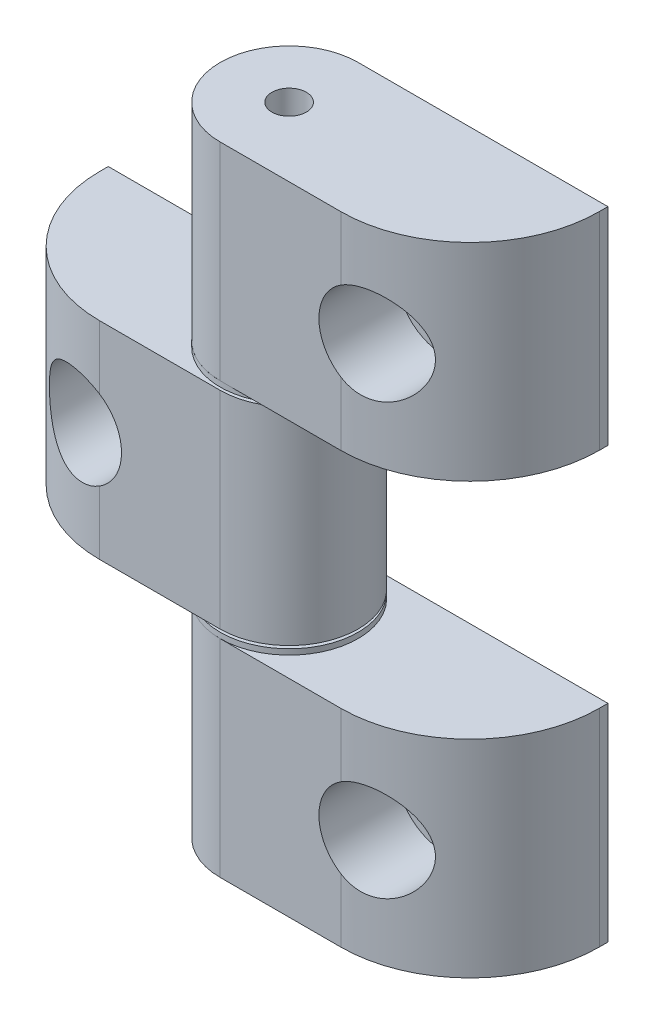
from build123d import *

# Parameters (mm, degrees)
SKETCH1_W           = 29.3624
SKETCH1_H           = 19.05
SKETCH1_R           = 2.413
EXTRUDE1_DEPTH      = 6.35
SKETCH2_R           = 4.191
SKETCH2_R_2         = 2.413
EXTRUDE2_DEPTH      = 2.159
SKETCH3_R           = 1.5875
CUT_EXTRUDE1_DEPTH  = 20.05
SKETCH4_R           = 4.3434
CUT_EXTRUDE2_DEPTH  = 7.1501
LPATTERN1_COUNT     = 2
LPATTERN1_PITCH     = 19.812
LPATTERN1_2_COUNT   = 2
LPATTERN1_2_PITCH   = 19.812
SKETCH5_R           = 6.35
SKETCH5_R_2         = 1.5875
EXTRUDE3_DEPTH      = 0.508
SKETCH6_R           = 6.35
SKETCH6_R_2         = 1.5875
EXTRUDE4_DEPTH      = 0.508
SKETCH7_R           = 1.5875
EXTRUDE5_DEPTH      = 19.431
EXTRUDE5_DEPTH_BACK = 19.431
CHAMFER1_SIZE       = 0.508


with BuildPart() as part:
    # Sketch1 → Extrude1 (new body, symmetric)
    with BuildSketch(Plane.XY):
        with Locations((5.1054, 0)):
            Rectangle(SKETCH1_W, SKETCH1_H)
        Circle(SKETCH1_R, mode=Mode.SUBTRACT)
    extrude(amount=EXTRUDE1_DEPTH, both=True)

    # Sketch2 → Extrude2 (add)
    with BuildSketch(Plane(origin=(0, 0, -6.35), x_dir=(-1, 0, 0), z_dir=(0, 0, -1))):
        Circle(SKETCH2_R)
        Circle(SKETCH2_R_2, mode=Mode.SUBTRACT)
    extrude(amount=EXTRUDE2_DEPTH)

    # Sketch3 → Cut-Extrude1 (cut, through all)
    with BuildSketch(Plane.XZ.offset(9.525)):
        with Locations((13.4366, 0)):
            Circle(SKETCH3_R)
        with BuildLine():
            Line((-9.5758, 6.35), (2.33045, 6.35))
            ThreePointArc((2.33045, 6.35), (-6.088540114, 2.862740114), (-9.5758, -5.55625))
            Line((-9.5758, -5.55625), (-9.5758, 6.35))
        make_face()
        with BuildLine():
            Line((13.4366, 6.35), (13.4366, 7.62))
            Line((13.4366, 7.62), (21.0566, 7.62))
            Line((21.0566, 7.62), (21.0566, -7.62))
            Line((21.0566, -7.62), (13.4366, -7.62))
            Line((13.4366, -7.62), (13.4366, -6.35))
            ThreePointArc((13.4366, -6.35), (19.7866, 0), (13.4366, 6.35))
        make_face()
    extrude(amount=-CUT_EXTRUDE1_DEPTH, mode=Mode.SUBTRACT)

    # Sketch4 → Cut-Extrude2 (cut)
    with BuildSketch(Plane.XY.offset(6.35)):
        Circle(SKETCH4_R)
    extrude(amount=-CUT_EXTRUDE2_DEPTH, mode=Mode.SUBTRACT)


with BuildPart() as body_2:
    # Mirror1: mirrored copy
    add(part.part.mirror(Plane(origin=(13.4366, 0, 0), x_dir=(0, 0, 1), z_dir=(1, 0, 0))))


with BuildPart() as lpattern1_1:
    # LPattern1: pattern copy
    add(body_2.part.moved(Location(Vector(0, -1, 0) * (1 * LPATTERN1_PITCH))))


with BuildPart() as lpattern1_2_1:
    # LPattern1 2: pattern copy
    add(body_2.part.moved(Location(Vector(0, 1, 0) * (1 * LPATTERN1_2_PITCH))))


with BuildPart() as lpattern1_2_2:
    # LPattern1 2: pattern copy
    add(lpattern1_1.part.moved(Location(Vector(0, 1, 0) * (1 * LPATTERN1_2_PITCH))))


with BuildPart() as body_4:
    # Sketch5 → Extrude3 (new body)
    with BuildSketch(Plane(origin=(0, -10.287, 0), x_dir=(1, 0, 0), z_dir=(0, 1, 0))):
        with Locations((13.4366, 0)):
            Circle(SKETCH5_R)
        with Locations((13.4366, 0)):
            Circle(SKETCH5_R_2, mode=Mode.SUBTRACT)
    extrude(amount=EXTRUDE3_DEPTH)



with BuildPart() as body_5:
    # Sketch6 → Extrude4 (new body)
    with BuildSketch(Plane.XZ.offset(-10.287)):
        with Locations((13.4366, 0)):
            Circle(SKETCH6_R)
        with Locations((13.4366, 0)):
            Circle(SKETCH6_R_2, mode=Mode.SUBTRACT)
    extrude(amount=EXTRUDE4_DEPTH)


with BuildPart() as body_4_1:
    add(body_4.part)

    add(body_5.part)  # Extrude5 merges body 5
    # Sketch7 → Extrude5 (add, two sides)
    with BuildSketch(Plane(origin=(0, 0, 0), x_dir=(1, 0, 0), z_dir=(0, 1, 0))) as extrude5_sk:
        with Locations((13.4366, 0)):
            Circle(SKETCH7_R)
    extrude(amount=EXTRUDE5_DEPTH)
    extrude(extrude5_sk.sketch, amount=-EXTRUDE5_DEPTH_BACK)

    # Chamfer1
    chamfer1_edges = [body_4_1.edges().sort_by_distance(p)[0] for p in [
        (11.8491, 19.431, 0),
        (11.8491, -19.431, 0),
    ]]
    chamfer(chamfer1_edges, length=CHAMFER1_SIZE)


solid = Compound([part.part, lpattern1_1.part, lpattern1_2_1.part, body_4_1.part])
